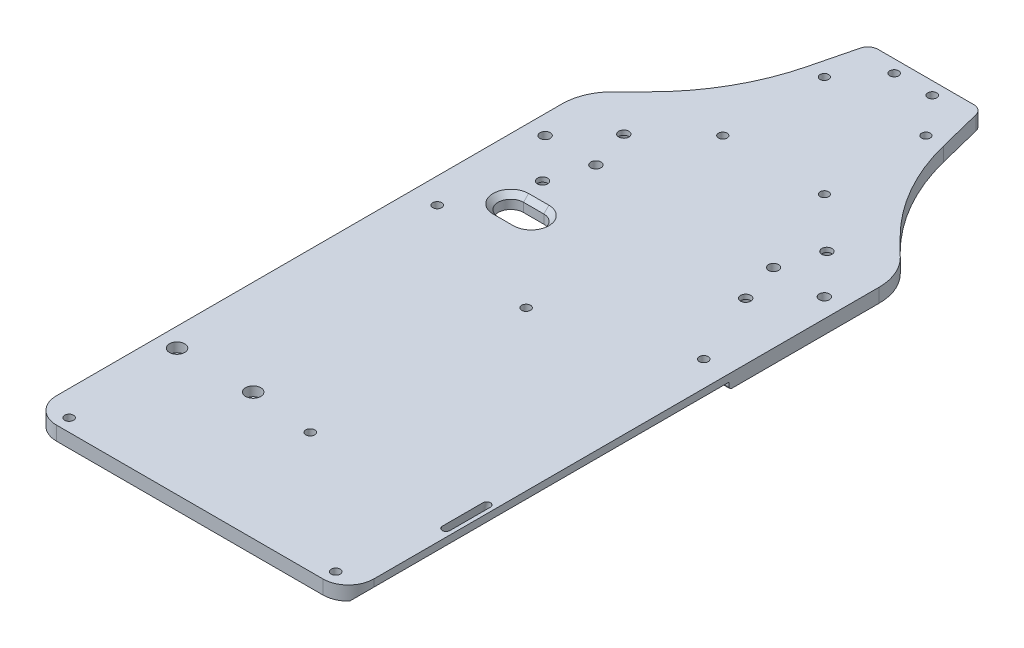
from build123d import *

# Parameters (mm, degrees)
DECK_BASE_DEPTH       = 5.5
BOLT_SLOT_REACH       = 7.5
SKETCH_3_R            = 1.75
FILLET_1_R            = 4
CUT_EXTRUDE_6_REACH   = 7.5
SKETCH_15_W           = 145
SKETCH_15_H           = 39
SKETCH_17_OUTSIDE_W   = 211.856
SKETCH_17_OUTSIDE_H   = 356.856
SKETCH_17_OUTSIDE_W_2 = 125
SKETCH_17_OUTSIDE_H_2 = 290
CUT_EXTRUDE_8_DEPTH   = 10
FILLET_4_R            = 10
FILLET_5_R            = 20
MOTOR_BOLT_DEPTH      = 10
CHAMFER_1_SIZE        = 2
SKETCH_22_R           = 2
CUT_EXTRUDE_9_DEPTH   = 10
LIDAR_SLOT_REACH      = 7.5
SKETCH_4_R            = 1.7
NANO_SLOT_REACH       = 7.5
SKETCH_7_R            = 1.75
CUT_EXTRUDE_3_REACH   = 7.5
SKETCH_12_R           = 1.75
SKETCH_13_R           = 3
CUT_EXTRUDE_4_DEPTH   = 3.7
SKETCH_23_R           = 3.05
CUT_EXTRUDE_10_DEPTH  = 3.7
CUT_EXTRUDE_12_REACH  = 3.889
SKETCH_25_W           = 150
SKETCH_25_H           = 10
FILLET_6_R            = 1


with BuildPart() as part:
    # 스케치1 → Deck base (new body)
    with BuildSketch(Plane(origin=(0, 0, 0), x_dir=(1, 0, 0), z_dir=(0, 1, 0))):
        with BuildLine():
            Line((-72.5, 0), (-72.5, -185))
            ThreePointArc((-72.5, -185), (-69.571067812, -192.071067812), (-62.5, -195))
            Line((-62.5, -195), (-49.962007487, -195))
            ThreePointArc((-49.962007487, -195), (-47.753248675, -195.514313374), (-45.998887542, -196.951446196))
            Line((-45.998887542, -196.951446196), (-19.001112458, -232.048553804))
            ThreePointArc((-19.001112458, -232.048553804), (-17.246751325, -233.485686626), (-15.037992513, -234))
            Line((-15.037992513, -234), (15.037992513, -234))
            ThreePointArc((15.037992513, -234), (17.246751325, -233.485686626), (19.001112458, -232.048553804))
            Line((19.001112458, -232.048553804), (45.998887542, -196.951446196))
            ThreePointArc((45.998887542, -196.951446196), (47.753248675, -195.514313374), (49.962007487, -195))
            Line((49.962007487, -195), (62.5, -195))
            ThreePointArc((62.5, -195), (69.571067812, -192.071067812), (72.5, -185))
            Line((72.5, -185), (72.5, 0))
            ThreePointArc((72.5, 0), (70.204904333, 11.508182998), (63.670781605, 21.255540601))
            Line((63.670781605, 21.255540601), (49.478231298, 35.391496426))
            ThreePointArc((49.478231298, 35.391496426), (35.536990456, 53.662264501), (27, 75))
            Line((27, 75), (22, 95))
            Line((22, 95), (-22, 95))
            Line((-22, 95), (-27, 75))
            ThreePointArc((-27, 75), (-35.536990456, 53.662264501), (-49.478231298, 35.391496426))
            Line((-49.478231298, 35.391496426), (-63.670781605, 21.255540601))
            ThreePointArc((-63.670781605, 21.255540601), (-70.204904333, 11.508182998), (-72.5, 0))
        make_face()
    extrude(amount=DECK_BASE_DEPTH)

    # 스케치3 → Bolt slot (cut, up to next)
    with BuildSketch(Plane(origin=(0, 5.5, 0), x_dir=(1, 0, 0), z_dir=(0, 1, 0)), mode=Mode.PRIVATE) as bolt_slot_sk1:
        with Locations((7.5, 90)):
            Circle(SKETCH_3_R)
    bolt_slot_tool1 = extrude(bolt_slot_sk1.sketch, amount=-BOLT_SLOT_REACH, mode=Mode.PRIVATE) & part.part
    add(bolt_slot_tool1.solids().sort_by_distance((7.5, 5.5, -90))[0], mode=Mode.SUBTRACT)
    # 스케치3 → Bolt slot (cut, up to next)
    with BuildSketch(Plane(origin=(0, 5.5, 0), x_dir=(1, 0, 0), z_dir=(0, 1, 0)), mode=Mode.PRIVATE) as bolt_slot_sk2:
        with Locations((-7.5, 90)):
            Circle(SKETCH_3_R)
    bolt_slot_tool2 = extrude(bolt_slot_sk2.sketch, amount=-BOLT_SLOT_REACH, mode=Mode.PRIVATE) & part.part
    add(bolt_slot_tool2.solids().sort_by_distance((-7.5, 5.5, -90))[0], mode=Mode.SUBTRACT)
    # 스케치3 → Bolt slot (cut, up to next)
    with BuildSketch(Plane(origin=(0, 5.5, 0), x_dir=(1, 0, 0), z_dir=(0, 1, 0)), mode=Mode.PRIVATE) as bolt_slot_sk3:
        with Locations((52.5, -45)):
            Circle(SKETCH_3_R)
    bolt_slot_tool3 = extrude(bolt_slot_sk3.sketch, amount=-BOLT_SLOT_REACH, mode=Mode.PRIVATE) & part.part
    add(bolt_slot_tool3.solids().sort_by_distance((52.5, 5.5, 45))[0], mode=Mode.SUBTRACT)
    # 스케치3 → Bolt slot (cut, up to next)
    with BuildSketch(Plane(origin=(0, 5.5, 0), x_dir=(1, 0, 0), z_dir=(0, 1, 0)), mode=Mode.PRIVATE) as bolt_slot_sk4:
        with Locations((52.5, -190)):
            Circle(SKETCH_3_R)
    bolt_slot_tool4 = extrude(bolt_slot_sk4.sketch, amount=-BOLT_SLOT_REACH, mode=Mode.PRIVATE) & part.part
    add(bolt_slot_tool4.solids().sort_by_distance((52.5, 5.5, 190))[0], mode=Mode.SUBTRACT)
    # 스케치3 → Bolt slot (cut, up to next)
    with BuildSketch(Plane(origin=(0, 5.5, 0), x_dir=(1, 0, 0), z_dir=(0, 1, 0)), mode=Mode.PRIVATE) as bolt_slot_sk5:
        with Locations((-52.5, -190)):
            Circle(SKETCH_3_R)
    bolt_slot_tool5 = extrude(bolt_slot_sk5.sketch, amount=-BOLT_SLOT_REACH, mode=Mode.PRIVATE) & part.part
    add(bolt_slot_tool5.solids().sort_by_distance((-52.5, 5.5, 190))[0], mode=Mode.SUBTRACT)
    # 스케치3 → Bolt slot (cut, up to next)
    with BuildSketch(Plane(origin=(0, 5.5, 0), x_dir=(1, 0, 0), z_dir=(0, 1, 0)), mode=Mode.PRIVATE) as bolt_slot_sk6:
        with Locations((-52.5, -45)):
            Circle(SKETCH_3_R)
    bolt_slot_tool6 = extrude(bolt_slot_sk6.sketch, amount=-BOLT_SLOT_REACH, mode=Mode.PRIVATE) & part.part
    add(bolt_slot_tool6.solids().sort_by_distance((-52.5, 5.5, 45))[0], mode=Mode.SUBTRACT)

    # 필렛1
    fillet_1_edges = [part.edges().sort_by_distance(p)[0] for p in [
        (22, 2.75, -95),
        (-22, 2.75, -95),
    ]]
    fillet(fillet_1_edges, radius=FILLET_1_R)

    # 스케치15 → 컷-돌출6 (cut, up to next)
    with BuildSketch(Plane(origin=(0, 5.5, 0), x_dir=(1, 0, 0), z_dir=(0, 1, 0)), mode=Mode.PRIVATE) as cut_extrude_6_sk1:
        with Locations((0, -214.5)):
            Rectangle(SKETCH_15_W, SKETCH_15_H)
    cut_extrude_6_tool1 = extrude(cut_extrude_6_sk1.sketch, amount=-CUT_EXTRUDE_6_REACH, mode=Mode.PRIVATE) & part.part
    add(cut_extrude_6_tool1.solids().sort_by_distance((0, 5.5, 214.5))[0], mode=Mode.SUBTRACT)

    # 스케치17 outside → 컷-돌출8 (cut)
    with BuildSketch(Plane(origin=(0, 5.5, 0), x_dir=(1, 0, 0), z_dir=(0, 1, 0))):
        with Locations((0, -50)):
            Rectangle(SKETCH_17_OUTSIDE_W, SKETCH_17_OUTSIDE_H)
        with Locations((0, -50)):
            Rectangle(SKETCH_17_OUTSIDE_W_2, SKETCH_17_OUTSIDE_H_2, mode=Mode.SUBTRACT)
    extrude(amount=-CUT_EXTRUDE_8_DEPTH, mode=Mode.SUBTRACT)

    # 필렛4
    fillet_4_edges = [part.edges().sort_by_distance(p)[0] for p in [
        (-62.5, 2.75, 195),
        (62.5, 2.75, 195),
    ]]
    fillet(fillet_4_edges, radius=FILLET_4_R)

    # 필렛5
    fillet_5_edges = [part.edges().sort_by_distance(p)[0] for p in [
        (-62.5, 2.75, -22.421653575),
        (62.5, 2.75, -22.421653575),
    ]]
    fillet(fillet_5_edges, radius=FILLET_5_R)

    # 스케치19 → Motor bolt (cut)
    with BuildSketch(Plane(origin=(0, 5.5, 0), x_dir=(1, 0, 0), z_dir=(0, 1, 0))):
        with BuildLine():
            Line((-38.5, -25), (-30.5, -25))
            ThreePointArc((-30.5, -25), (-25.5, -30), (-30.5, -35))
            Line((-30.5, -35), (-38.5, -35))
            ThreePointArc((-38.5, -35), (-43.5, -30), (-38.5, -25))
        make_face()
    extrude(amount=-MOTOR_BOLT_DEPTH, mode=Mode.SUBTRACT)

    # 모따기1
    chamfer_1_edges = [part.edges().sort_by_distance(p)[0] for p in [
        (-43.5, 5.5, 30),
        (-34.5, 5.5, 35),
        (-25.5, 5.5, 30),
        (-34.5, 5.5, 25),
    ]]
    chamfer(chamfer_1_edges, length=CHAMFER_1_SIZE)

    # 스케치22 → 컷-돌출9 (cut)
    with BuildSketch(Plane(origin=(0, 5.5, 0), x_dir=(1, 0, 0), z_dir=(0, 1, 0))):
        with Locations((-54.999999999, 0)):
            Circle(SKETCH_22_R)
        with Locations((-34.999999999, 0)):
            Circle(SKETCH_22_R)
        with Locations((-40, 16)):
            Circle(SKETCH_22_R)
        with Locations((40, 16)):
            Circle(SKETCH_22_R)
        with Locations((34.999999999, 0)):
            Circle(SKETCH_22_R)
        with Locations((54.999999999, 0)):
            Circle(SKETCH_22_R)
        with Locations((40, -16)):
            Circle(SKETCH_22_R)
        with Locations((-40, -16)):
            Circle(SKETCH_22_R)
    extrude(amount=-CUT_EXTRUDE_9_DEPTH, mode=Mode.SUBTRACT)

    # 스케치4 → Lidar slot (cut, up to next)
    with BuildSketch(Plane(origin=(0, 5.5, 0), x_dir=(1, 0, 0), z_dir=(0, 1, 0)), mode=Mode.PRIVATE) as lidar_slot_sk1:
        with Locations((-20, 75)):
            Circle(SKETCH_4_R)
    lidar_slot_tool1 = extrude(lidar_slot_sk1.sketch, amount=-LIDAR_SLOT_REACH, mode=Mode.PRIVATE) & part.part
    add(lidar_slot_tool1.solids().sort_by_distance((-20, 5.5, -75))[0], mode=Mode.SUBTRACT)
    # 스케치4 → Lidar slot (cut, up to next)
    with BuildSketch(Plane(origin=(0, 5.5, 0), x_dir=(1, 0, 0), z_dir=(0, 1, 0)), mode=Mode.PRIVATE) as lidar_slot_sk2:
        with Locations((-20, 35)):
            Circle(SKETCH_4_R)
    lidar_slot_tool2 = extrude(lidar_slot_sk2.sketch, amount=-LIDAR_SLOT_REACH, mode=Mode.PRIVATE) & part.part
    add(lidar_slot_tool2.solids().sort_by_distance((-20, 5.5, -35))[0], mode=Mode.SUBTRACT)
    # 스케치4 → Lidar slot (cut, up to next)
    with BuildSketch(Plane(origin=(0, 5.5, 0), x_dir=(1, 0, 0), z_dir=(0, 1, 0)), mode=Mode.PRIVATE) as lidar_slot_sk3:
        with Locations((20, 35)):
            Circle(SKETCH_4_R)
    lidar_slot_tool3 = extrude(lidar_slot_sk3.sketch, amount=-LIDAR_SLOT_REACH, mode=Mode.PRIVATE) & part.part
    add(lidar_slot_tool3.solids().sort_by_distance((20, 5.5, -35))[0], mode=Mode.SUBTRACT)
    # 스케치4 → Lidar slot (cut, up to next)
    with BuildSketch(Plane(origin=(0, 5.5, 0), x_dir=(1, 0, 0), z_dir=(0, 1, 0)), mode=Mode.PRIVATE) as lidar_slot_sk4:
        with Locations((20, 75)):
            Circle(SKETCH_4_R)
    lidar_slot_tool4 = extrude(lidar_slot_sk4.sketch, amount=-LIDAR_SLOT_REACH, mode=Mode.PRIVATE) & part.part
    add(lidar_slot_tool4.solids().sort_by_distance((20, 5.5, -75))[0], mode=Mode.SUBTRACT)

    # 스케치7 → Nano slot (cut, up to next)
    with BuildSketch(Plane(origin=(0, 5.5, 0), x_dir=(1, 0, 0), z_dir=(0, 1, 0)), mode=Mode.PRIVATE) as nano_slot_sk1:
        with Locations((0, -62.5)):
            Circle(SKETCH_7_R)
    nano_slot_tool1 = extrude(nano_slot_sk1.sketch, amount=-NANO_SLOT_REACH, mode=Mode.PRIVATE) & part.part
    add(nano_slot_tool1.solids().sort_by_distance((0, 5.5, 62.5))[0], mode=Mode.SUBTRACT)
    # 스케치7 → Nano slot (cut, up to next)
    with BuildSketch(Plane(origin=(0, 5.5, 0), x_dir=(1, 0, 0), z_dir=(0, 1, 0)), mode=Mode.PRIVATE) as nano_slot_sk2:
        with Locations((0, -147.5)):
            Circle(SKETCH_7_R)
    nano_slot_tool2 = extrude(nano_slot_sk2.sketch, amount=-NANO_SLOT_REACH, mode=Mode.PRIVATE) & part.part
    add(nano_slot_tool2.solids().sort_by_distance((0, 5.5, 147.5))[0], mode=Mode.SUBTRACT)

    # 스케치12 → 컷-돌출3 (cut, up to next)
    with BuildSketch(Plane(origin=(0, 5.5, 0), x_dir=(1, 0, 0), z_dir=(0, 1, 0)), mode=Mode.PRIVATE) as cut_extrude_3_sk1:
        with Locations((-55, -145)):
            Circle(SKETCH_12_R)
    cut_extrude_3_tool1 = extrude(cut_extrude_3_sk1.sketch, amount=-CUT_EXTRUDE_3_REACH, mode=Mode.PRIVATE) & part.part
    add(cut_extrude_3_tool1.solids().sort_by_distance((-55, 5.5, 145))[0], mode=Mode.SUBTRACT)
    # 스케치12 → 컷-돌출3 (cut, up to next)
    with BuildSketch(Plane(origin=(0, 5.5, 0), x_dir=(1, 0, 0), z_dir=(0, 1, 0)), mode=Mode.PRIVATE) as cut_extrude_3_sk2:
        with Locations((-25, -145)):
            Circle(SKETCH_12_R)
    cut_extrude_3_tool2 = extrude(cut_extrude_3_sk2.sketch, amount=-CUT_EXTRUDE_3_REACH, mode=Mode.PRIVATE) & part.part
    add(cut_extrude_3_tool2.solids().sort_by_distance((-25, 5.5, 145))[0], mode=Mode.SUBTRACT)

    # 스케치13 → 컷-돌출4 (cut)
    with BuildSketch(Plane(origin=(0, 5.5, 0), x_dir=(1, 0, 0), z_dir=(0, 1, 0))):
        with Locations((-55, -145)):
            Circle(SKETCH_13_R)
        with Locations((-25, -145)):
            Circle(SKETCH_13_R)
    extrude(amount=-CUT_EXTRUDE_4_DEPTH, mode=Mode.SUBTRACT)

    # 스케치23 → 컷-돌출10 (cut)
    with BuildSketch(Plane.XZ):
        with Locations((40, 16)):
            Circle(SKETCH_23_R)
        with Locations((40, -16)):
            Circle(SKETCH_23_R)
        with Locations((-40, -16)):
            Circle(SKETCH_23_R)
        with Locations((-40, 16)):
            Circle(SKETCH_23_R)
    extrude(amount=-CUT_EXTRUDE_10_DEPTH, mode=Mode.SUBTRACT)

    # 스케치25 → 컷-돌출12 (cut, up to next)
    with BuildSketch(Plane(origin=(29.914213562, -29.914213562, 0), x_dir=(0, 0, -1), z_dir=(0.707106781, -0.707106781, 0)), mode=Mode.PRIVATE) as cut_extrude_12_sk1:
        with Locations((-120, 43.083261121)):
            Rectangle(SKETCH_25_W, SKETCH_25_H)
    cut_extrude_12_tool1 = extrude(cut_extrude_12_sk1.sketch, amount=CUT_EXTRUDE_12_REACH, mode=Mode.PRIVATE) & part.part
    add(cut_extrude_12_tool1.solids().sort_by_distance((60.37868, 0.550253, 120))[0], mode=Mode.SUBTRACT)

    # 필렛6
    fillet_6_edges = [part.edges().sort_by_distance(p)[0] for p in [
        (61.164213562, 0, 45),
    ]]
    fillet(fillet_6_edges, radius=FILLET_6_R)

    # 스케치26 → 컷-로프트2 section 0
    with BuildSketch(Plane.XZ):
        with BuildLine():
            Line((56.828427125, 153.5), (56.828427125, 137.5))
            ThreePointArc((56.828427125, 137.5), (58.328427125, 136), (59.828427125, 137.5))
            Line((59.828427125, 137.5), (59.828427125, 153.5))
            ThreePointArc((59.828427125, 153.5), (58.328427125, 155), (56.828427125, 153.5))
        make_face()
    # 스케치27 → 컷-로프트2 section 1
    with BuildSketch(Plane(origin=(0, 5.5, 0), x_dir=(1, 0, 0), z_dir=(0, 1, 0))):
        with BuildLine():
            Line((58, -137.5), (58, -153.5))
            ThreePointArc((58, -153.5), (59.5, -155), (61, -153.5))
            Line((61, -153.5), (61, -137.5))
            ThreePointArc((61, -137.5), (59.5, -136), (58, -137.5))
        make_face()
    loft(mode=Mode.SUBTRACT)


solid = part.part
